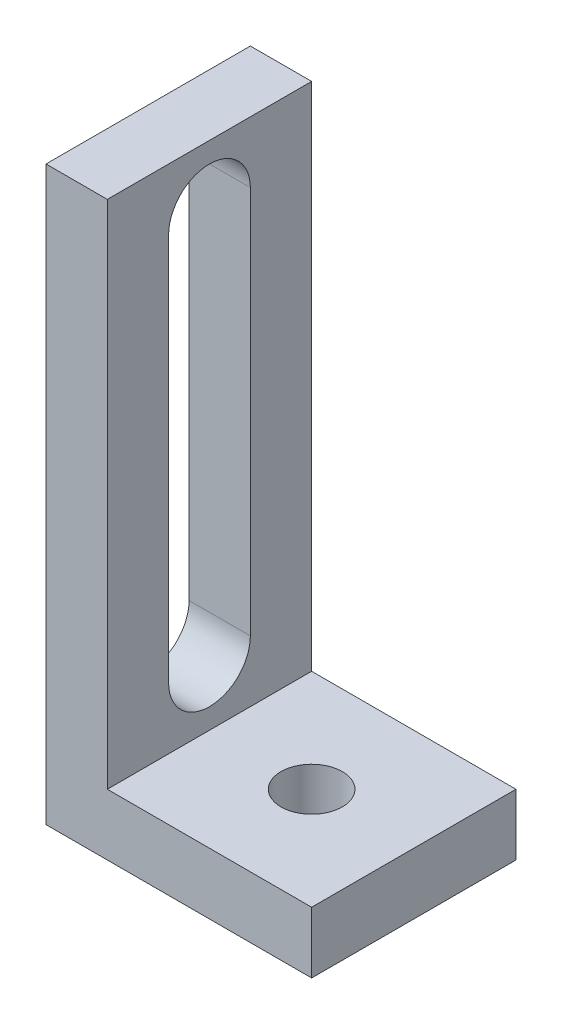
from build123d import *

# Parameters (mm, degrees)
SKETCH_2_W          = 10
SKETCH_2_H          = 10
EXTRUDE_2_DEPTH     = 3
SKETCH_3_R          = 1.5
CUT_EXTRUDE_1_DEPTH = 3
EXTRUDE_3_DEPTH     = 10
CUT_EXTRUDE_2_DEPTH = 10


with BuildPart() as part:
    # 草图2 → 凸台-拉伸2 (new body)
    with BuildSketch(Plane(origin=(0, 0, 0), x_dir=(1, 0, 0), z_dir=(0, 1, 0))):
        with Locations((5, -5)):
            Rectangle(SKETCH_2_W, SKETCH_2_H)
    extrude(amount=EXTRUDE_2_DEPTH)

    # 草图3 → 切除-拉伸1 (cut)
    with BuildSketch(Plane(origin=(0, 3, 0), x_dir=(1, 0, 0), z_dir=(0, 1, 0))):
        with Locations((5, -5)):
            Circle(SKETCH_3_R)
    extrude(amount=-CUT_EXTRUDE_1_DEPTH, mode=Mode.SUBTRACT)

    # 草图5 → 凸台-拉伸3 (add, through all)
    with BuildSketch(Plane.XY.offset(10)):
        Polygon((0, 3), (0, 28), (-3, 28), (-3, 0), (0, 0), align=None)
    extrude(amount=-EXTRUDE_3_DEPTH)

    # 草图6 → 切除-拉伸2 (cut)
    with BuildSketch(Plane(origin=(0, 0, 0), x_dir=(0, 0, -1), z_dir=(1, 0, 0))):
        with BuildLine():
            Line((-3, 25), (-3, 6))
            ThreePointArc((-3, 6), (-5, 4), (-7, 6))
            Line((-7, 6), (-7, 25))
            ThreePointArc((-7, 25), (-5, 27), (-3, 25))
        make_face()
    extrude(amount=-CUT_EXTRUDE_2_DEPTH, mode=Mode.SUBTRACT)


solid = part.part
